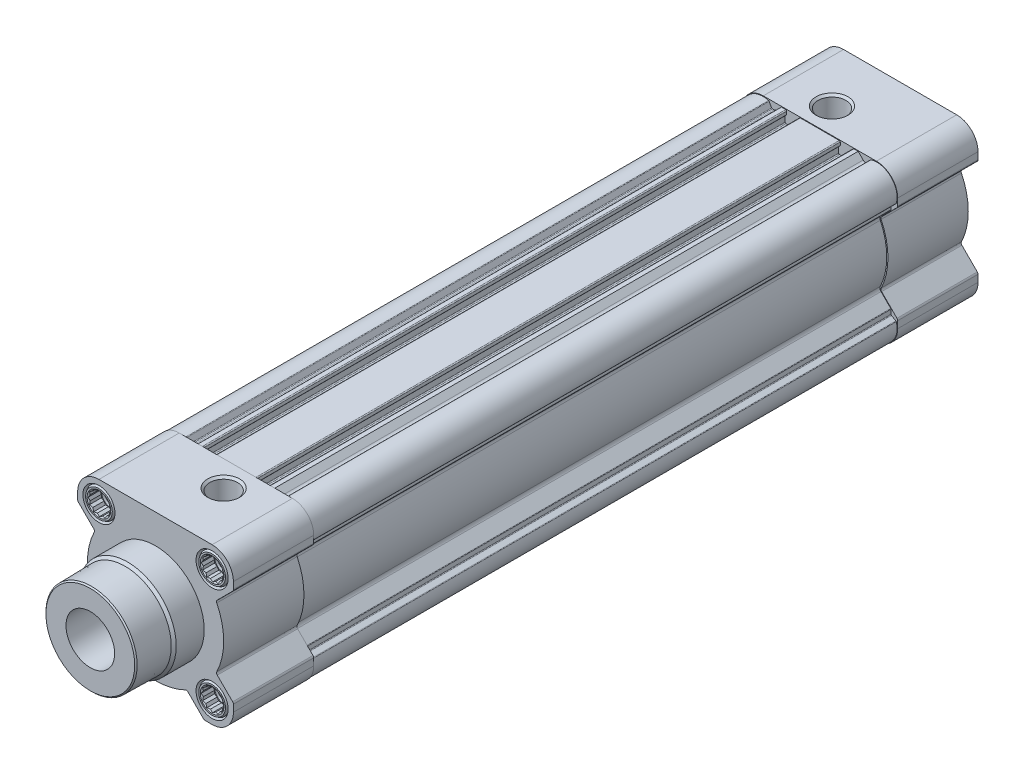
from build123d import *

# Parameters (mm, degrees)
BOSS_EXTRUDE1_DEPTH  = 33
BOSS_EXTRUDE2_DEPTH  = 240
SKETCH3_W            = 76.8
SKETCH3_H            = 76.8
CUT_EXTRUDE1_DEPTH   = 240
BOSS_EXTRUDE3_DEPTH  = 33
SKETCH7_W            = 24.5
SKETCH7_H            = 6.6
LPATTERN1_COUNT      = 2
LPATTERN1_PITCH      = 46.5
LPATTERN1_COUNT_DIR2 = 2
LPATTERN1_PITCH_DIR2 = 46.5
LPATTERN2_COUNT      = 2
LPATTERN2_PITCH      = 46.5
LPATTERN2_COUNT_DIR2 = 2
LPATTERN2_PITCH_DIR2 = 46.5
CUT_EXTRUDE2_DEPTH   = 5
LPATTERN3_COUNT      = 2
LPATTERN3_PITCH      = 46.5
LPATTERN3_COUNT_DIR2 = 2
LPATTERN3_PITCH_DIR2 = 46.5
LPATTERN4_COUNT      = 2
LPATTERN4_PITCH      = 46.5
LPATTERN4_COUNT_DIR2 = 2
LPATTERN4_PITCH_DIR2 = 46.5
SKETCH17_W           = 24.5
SKETCH17_H           = 6.6
LPATTERN5_COUNT      = 2
LPATTERN5_PITCH      = 46.5
LPATTERN5_COUNT_DIR2 = 2
LPATTERN5_PITCH_DIR2 = 46.5
LPATTERN6_COUNT      = 2
LPATTERN6_PITCH      = 46.5
LPATTERN6_COUNT_DIR2 = 2
LPATTERN6_PITCH_DIR2 = 46.5
LPATTERN7_COUNT      = 2
LPATTERN7_PITCH      = 46.5
LPATTERN7_COUNT_DIR2 = 2
LPATTERN7_PITCH_DIR2 = 46.5
CUT_EXTRUDE3_DEPTH   = 5
LPATTERN8_COUNT      = 2
LPATTERN8_PITCH      = 46.5
LPATTERN8_COUNT_DIR2 = 2
LPATTERN8_PITCH_DIR2 = 46.5


with BuildPart() as part:
    # Sketch1 → Boss-Extrude1 (new body)
    with BuildSketch(Plane.XY.offset(-33)):
        with BuildLine():
            Line((-31.707106781, 19.686291501), (-25.38500441, 13.36418913))
            ThreePointArc((-25.38500441, 13.36418913), (-25.10600235, 12.82318278), (-25.192383219, 12.220631233))
            ThreePointArc((-25.192383219, 12.220631233), (-28, 0), (-25.192383219, -12.220631233))
            ThreePointArc((-25.192383219, -12.220631233), (-25.10600235, -12.82318278), (-25.38500441, -13.36418913))
            Line((-25.38500441, -13.36418913), (-31.707106781, -19.686291501))
            ThreePointArc((-31.707106781, -19.686291501), (-31.923879533, -20.01071485), (-32, -20.393398282))
            Line((-32, -20.393398282), (-32, -23.25))
            ThreePointArc((-32, -23.25), (-29.437184335, -29.437184335), (-23.25, -32))
            Line((-23.25, -32), (-20.393398282, -32))
            ThreePointArc((-20.393398282, -32), (-20.01071485, -31.923879533), (-19.686291501, -31.707106781))
            Line((-19.686291501, -31.707106781), (-13.36418913, -25.38500441))
            ThreePointArc((-13.36418913, -25.38500441), (-12.82318278, -25.10600235), (-12.220631233, -25.192383219))
            ThreePointArc((-12.220631233, -25.192383219), (0, -28), (12.220631233, -25.192383219))
            ThreePointArc((12.220631233, -25.192383219), (12.82318278, -25.10600235), (13.36418913, -25.38500441))
            Line((13.36418913, -25.38500441), (19.686291501, -31.707106781))
            ThreePointArc((19.686291501, -31.707106781), (20.01071485, -31.923879533), (20.393398282, -32))
            Line((20.393398282, -32), (23.25, -32))
            ThreePointArc((23.25, -32), (29.437184335, -29.437184335), (32, -23.25))
            Line((32, -23.25), (32, -20.393398282))
            ThreePointArc((32, -20.393398282), (31.923879533, -20.01071485), (31.707106781, -19.686291501))
            Line((31.707106781, -19.686291501), (25.38500441, -13.36418913))
            ThreePointArc((25.38500441, -13.36418913), (25.10600235, -12.82318278), (25.192383219, -12.220631233))
            ThreePointArc((25.192383219, -12.220631233), (28, 0), (25.192383219, 12.220631233))
            ThreePointArc((25.192383219, 12.220631233), (25.10600235, 12.82318278), (25.38500441, 13.36418913))
            Line((25.38500441, 13.36418913), (31.707106781, 19.686291501))
            ThreePointArc((31.707106781, 19.686291501), (31.923879533, 20.01071485), (32, 20.393398282))
            Line((32, 20.393398282), (32, 23.25))
            ThreePointArc((32, 23.25), (29.437184335, 29.437184335), (23.25, 32))
            Line((23.25, 32), (-23.25, 32))
            ThreePointArc((-23.25, 32), (-29.437184335, 29.437184335), (-32, 23.25))
            Line((-32, 23.25), (-32, 20.393398282))
            ThreePointArc((-32, 20.393398282), (-31.923879533, 20.01071485), (-31.707106781, 19.686291501))
        make_face()
    extrude(amount=BOSS_EXTRUDE1_DEPTH)

    # Sketch2 → Boss-Extrude2 (add)
    with BuildSketch(Plane.XY.offset(-33)):
        with BuildLine():
            Line((-31.75, -20.08273811), (-31.75, -23.5))
            ThreePointArc((-31.75, -23.5), (-29.333630945, -29.333630945), (-23.5, -31.75))
            Line((-23.5, -31.75), (-20.08273811, -31.75))
            Line((-20.08273811, -31.75), (-13.628865041, -25.296126931))
            ThreePointArc((-13.628865041, -25.296126931), (-12.822305384, -24.87846612), (-11.922577907, -25.00284256))
            ThreePointArc((-11.922577907, -25.00284256), (0, -27.7), (11.922577907, -25.00284256))
            ThreePointArc((11.922577907, -25.00284256), (12.822305384, -24.87846612), (13.628865041, -25.296126931))
            Line((13.628865041, -25.296126931), (20.08273811, -31.75))
            Line((20.08273811, -31.75), (23.5, -31.75))
            ThreePointArc((23.5, -31.75), (29.333630945, -29.333630945), (31.75, -23.5))
            Line((31.75, -23.5), (31.75, -20.08273811))
            Line((31.75, -20.08273811), (25.296126931, -13.628865041))
            ThreePointArc((25.296126931, -13.628865041), (24.87846612, -12.822305384), (25.00284256, -11.922577907))
            ThreePointArc((25.00284256, -11.922577907), (27.7, 0), (25.00284256, 11.922577907))
            ThreePointArc((25.00284256, 11.922577907), (24.87846612, 12.822305384), (25.296126931, 13.628865041))
            Line((25.296126931, 13.628865041), (31.75, 20.08273811))
            Line((31.75, 20.08273811), (31.75, 23.5))
            ThreePointArc((31.75, 23.5), (29.333630945, 29.333630945), (23.5, 31.75))
            Line((23.5, 31.75), (-23.5, 31.75))
            ThreePointArc((-23.5, 31.75), (-29.333630945, 29.333630945), (-31.75, 23.5))
            Line((-31.75, 23.5), (-31.75, 20.08273811))
            Line((-31.75, 20.08273811), (-25.296126931, 13.628865041))
            ThreePointArc((-25.296126931, 13.628865041), (-24.87846612, 12.822305384), (-25.00284256, 11.922577907))
            ThreePointArc((-25.00284256, 11.922577907), (-27.7, 0), (-25.00284256, -11.922577907))
            ThreePointArc((-25.00284256, -11.922577907), (-24.87846612, -12.822305384), (-25.296126931, -13.628865041))
            Line((-25.296126931, -13.628865041), (-31.75, -20.08273811))
        make_face()
    extrude(amount=-BOSS_EXTRUDE2_DEPTH)

    # Sketch3 → Cut-Extrude1 (cut)
    with BuildSketch(Plane.XY.offset(-33)):
        Rectangle(SKETCH3_W, SKETCH3_H)
        with BuildLine():
            Line((-20.847700821, -31.237836974), (-19.815492663, -29.45))
            ThreePointArc((-19.815492663, -29.45), (-19.669082502, -29.303589838), (-19.469082502, -29.25))
            Line((-19.469082502, -29.25), (-17.748423535, -29.25))
            ThreePointArc((-17.748423535, -29.25), (-17.595350162, -29.219551813), (-17.465580823, -29.132842712))
            Line((-17.465580823, -29.132842712), (-13.478767922, -25.146029812))
            ThreePointArc((-13.478767922, -25.146029812), (-12.674014627, -24.728680623), (-11.775791832, -24.851171536))
            ThreePointArc((-11.775791832, -24.851171536), (0, -27.5), (11.775791832, -24.851171536))
            ThreePointArc((11.775791832, -24.851171536), (12.674014627, -24.728680623), (13.478767922, -25.146029812))
            Line((13.478767922, -25.146029812), (17.465580823, -29.132842712))
            ThreePointArc((17.465580823, -29.132842712), (17.595350162, -29.219551813), (17.748423535, -29.25))
            Line((17.748423535, -29.25), (19.469082502, -29.25))
            ThreePointArc((19.469082502, -29.25), (19.669082502, -29.303589838), (19.815492663, -29.45))
            Line((19.815492663, -29.45), (20.847700821, -31.237836974))
            ThreePointArc((20.847700821, -31.237836974), (20.947545902, -31.352806276), (21.083122856, -31.422130658))
            ThreePointArc((21.083122856, -31.422130658), (29.304341623, -29.304341623), (31.422130658, -21.083122856))
            ThreePointArc((31.422130658, -21.083122856), (31.352806276, -20.947545902), (31.237836974, -20.847700821))
            Line((31.237836974, -20.847700821), (29.45, -19.815492663))
            ThreePointArc((29.45, -19.815492663), (29.303589838, -19.669082502), (29.25, -19.469082502))
            Line((29.25, -19.469082502), (29.25, -17.748423535))
            ThreePointArc((29.25, -17.748423535), (29.219551813, -17.595350162), (29.132842712, -17.465580823))
            Line((29.132842712, -17.465580823), (25.146029812, -13.478767922))
            ThreePointArc((25.146029812, -13.478767922), (24.728680623, -12.674014627), (24.851171536, -11.775791832))
            ThreePointArc((24.851171536, -11.775791832), (27.5, 0), (24.851171536, 11.775791832))
            ThreePointArc((24.851171536, 11.775791832), (24.728680623, 12.674014627), (25.146029812, 13.478767922))
            Line((25.146029812, 13.478767922), (29.132842712, 17.465580823))
            ThreePointArc((29.132842712, 17.465580823), (29.219551813, 17.595350162), (29.25, 17.748423535))
            Line((29.25, 17.748423535), (29.25, 19.469082502))
            ThreePointArc((29.25, 19.469082502), (29.303589838, 19.669082502), (29.45, 19.815492663))
            Line((29.45, 19.815492663), (31.237836974, 20.847700821))
            ThreePointArc((31.237836974, 20.847700821), (31.352806276, 20.947545902), (31.422130658, 21.083122856))
            ThreePointArc((31.422130658, 21.083122856), (29.304341623, 29.304341623), (21.083122856, 31.422130658))
            ThreePointArc((21.083122856, 31.422130658), (20.947545902, 31.352806276), (20.847700821, 31.237836974))
            Line((20.847700821, 31.237836974), (19.815492663, 29.45))
            ThreePointArc((19.815492663, 29.45), (19.669082502, 29.303589838), (19.469082502, 29.25))
            Line((19.469082502, 29.25), (18.871320344, 29.25))
            ThreePointArc((18.871320344, 29.25), (18.297295195, 29.364180701), (17.810660172, 29.689339828))
            Line((17.810660172, 29.689339828), (15.75, 31.75))
            Line((15.75, 31.75), (14, 31.75))
            ThreePointArc((14, 31.75), (13.717157288, 31.632842712), (13.6, 31.35))
            Line((13.6, 31.35), (13.6, 30.15))
            ThreePointArc((13.6, 30.15), (13.658578644, 30.008578644), (13.8, 29.95))
            Line((13.8, 29.95), (14.05, 29.95))
            ThreePointArc((14.05, 29.95), (14.191421356, 29.891421356), (14.25, 29.75))
            Line((14.25, 29.75), (14.25, 27.15))
            ThreePointArc((14.25, 27.15), (14.132842712, 26.867157288), (13.85, 26.75))
            Line((13.85, 26.75), (8.15, 26.75))
            ThreePointArc((8.15, 26.75), (7.867157288, 26.867157288), (7.75, 27.15))
            Line((7.75, 27.15), (7.75, 29.75))
            ThreePointArc((7.75, 29.75), (7.808578644, 29.891421356), (7.95, 29.95))
            Line((7.95, 29.95), (8.2, 29.95))
            ThreePointArc((8.2, 29.95), (8.341421356, 30.008578644), (8.4, 30.15))
            Line((8.4, 30.15), (8.4, 31.35))
            ThreePointArc((8.4, 31.35), (8.282842712, 31.632842712), (8, 31.75))
            Line((8, 31.75), (-8, 31.75))
            ThreePointArc((-8, 31.75), (-8.282842712, 31.632842712), (-8.4, 31.35))
            Line((-8.4, 31.35), (-8.4, 30.15))
            ThreePointArc((-8.4, 30.15), (-8.341421356, 30.008578644), (-8.2, 29.95))
            Line((-8.2, 29.95), (-7.95, 29.95))
            ThreePointArc((-7.95, 29.95), (-7.808578644, 29.891421356), (-7.75, 29.75))
            Line((-7.75, 29.75), (-7.75, 27.15))
            ThreePointArc((-7.75, 27.15), (-7.867157288, 26.867157288), (-8.15, 26.75))
            Line((-8.15, 26.75), (-13.85, 26.75))
            ThreePointArc((-13.85, 26.75), (-14.132842712, 26.867157288), (-14.25, 27.15))
            Line((-14.25, 27.15), (-14.25, 29.75))
            ThreePointArc((-14.25, 29.75), (-14.191421356, 29.891421356), (-14.05, 29.95))
            Line((-14.05, 29.95), (-13.8, 29.95))
            ThreePointArc((-13.8, 29.95), (-13.658578644, 30.008578644), (-13.6, 30.15))
            Line((-13.6, 30.15), (-13.6, 31.35))
            ThreePointArc((-13.6, 31.35), (-13.717157288, 31.632842712), (-14, 31.75))
            Line((-14, 31.75), (-15.75, 31.75))
            Line((-15.75, 31.75), (-17.810660172, 29.689339828))
            ThreePointArc((-17.810660172, 29.689339828), (-18.297295195, 29.364180701), (-18.871320344, 29.25))
            Line((-18.871320344, 29.25), (-19.469082502, 29.25))
            ThreePointArc((-19.469082502, 29.25), (-19.669082502, 29.303589838), (-19.815492663, 29.45))
            Line((-19.815492663, 29.45), (-20.847700821, 31.237836974))
            ThreePointArc((-20.847700821, 31.237836974), (-20.947545902, 31.352806276), (-21.083122856, 31.422130658))
            ThreePointArc((-21.083122856, 31.422130658), (-29.304341623, 29.304341623), (-31.422130658, 21.083122856))
            ThreePointArc((-31.422130658, 21.083122856), (-31.352806276, 20.947545902), (-31.237836974, 20.847700821))
            Line((-31.237836974, 20.847700821), (-29.45, 19.815492663))
            ThreePointArc((-29.45, 19.815492663), (-29.303589838, 19.669082502), (-29.25, 19.469082502))
            Line((-29.25, 19.469082502), (-29.25, 17.748423535))
            ThreePointArc((-29.25, 17.748423535), (-29.219551813, 17.595350162), (-29.132842712, 17.465580823))
            Line((-29.132842712, 17.465580823), (-25.146029812, 13.478767922))
            ThreePointArc((-25.146029812, 13.478767922), (-24.728680623, 12.674014627), (-24.851171536, 11.775791832))
            ThreePointArc((-24.851171536, 11.775791832), (-27.5, 0), (-24.851171536, -11.775791832))
            ThreePointArc((-24.851171536, -11.775791832), (-24.728680623, -12.674014627), (-25.146029812, -13.478767922))
            Line((-25.146029812, -13.478767922), (-29.132842712, -17.465580823))
            ThreePointArc((-29.132842712, -17.465580823), (-29.219551813, -17.595350162), (-29.25, -17.748423535))
            Line((-29.25, -17.748423535), (-29.25, -19.469082502))
            ThreePointArc((-29.25, -19.469082502), (-29.303589838, -19.669082502), (-29.45, -19.815492663))
            Line((-29.45, -19.815492663), (-31.237836974, -20.847700821))
            ThreePointArc((-31.237836974, -20.847700821), (-31.352806276, -20.947545902), (-31.422130658, -21.083122856))
            ThreePointArc((-31.422130658, -21.083122856), (-29.304341623, -29.304341623), (-21.083122856, -31.422130658))
            ThreePointArc((-21.083122856, -31.422130658), (-20.947545902, -31.352806276), (-20.847700821, -31.237836974))
        make_face(mode=Mode.SUBTRACT)
    extrude(amount=-CUT_EXTRUDE1_DEPTH, mode=Mode.SUBTRACT)

    # Sketch4 → Boss-Extrude3 (add)
    with BuildSketch(Plane.XY.offset(-306)):
        with BuildLine():
            Line((-31.707106781, 19.686291501), (-25.38500441, 13.36418913))
            ThreePointArc((-25.38500441, 13.36418913), (-25.10600235, 12.82318278), (-25.192383219, 12.220631233))
            ThreePointArc((-25.192383219, 12.220631233), (-28, 0), (-25.192383219, -12.220631233))
            ThreePointArc((-25.192383219, -12.220631233), (-25.10600235, -12.82318278), (-25.38500441, -13.36418913))
            Line((-25.38500441, -13.36418913), (-31.707106781, -19.686291501))
            ThreePointArc((-31.707106781, -19.686291501), (-31.923879533, -20.01071485), (-32, -20.393398282))
            Line((-32, -20.393398282), (-32, -23.25))
            ThreePointArc((-32, -23.25), (-29.437184335, -29.437184335), (-23.25, -32))
            Line((-23.25, -32), (-20.393398282, -32))
            ThreePointArc((-20.393398282, -32), (-20.01071485, -31.923879533), (-19.686291501, -31.707106781))
            Line((-19.686291501, -31.707106781), (-13.36418913, -25.38500441))
            ThreePointArc((-13.36418913, -25.38500441), (-12.82318278, -25.10600235), (-12.220631233, -25.192383219))
            ThreePointArc((-12.220631233, -25.192383219), (0, -28), (12.220631233, -25.192383219))
            ThreePointArc((12.220631233, -25.192383219), (12.82318278, -25.10600235), (13.36418913, -25.38500441))
            Line((13.36418913, -25.38500441), (19.686291501, -31.707106781))
            ThreePointArc((19.686291501, -31.707106781), (20.01071485, -31.923879533), (20.393398282, -32))
            Line((20.393398282, -32), (23.25, -32))
            ThreePointArc((23.25, -32), (29.437184335, -29.437184335), (32, -23.25))
            Line((32, -23.25), (32, -20.393398282))
            ThreePointArc((32, -20.393398282), (31.923879533, -20.01071485), (31.707106781, -19.686291501))
            Line((31.707106781, -19.686291501), (25.38500441, -13.36418913))
            ThreePointArc((25.38500441, -13.36418913), (25.10600235, -12.82318278), (25.192383219, -12.220631233))
            ThreePointArc((25.192383219, -12.220631233), (28, 0), (25.192383219, 12.220631233))
            ThreePointArc((25.192383219, 12.220631233), (25.10600235, 12.82318278), (25.38500441, 13.36418913))
            Line((25.38500441, 13.36418913), (31.707106781, 19.686291501))
            ThreePointArc((31.707106781, 19.686291501), (31.923879533, 20.01071485), (32, 20.393398282))
            Line((32, 20.393398282), (32, 23.25))
            ThreePointArc((32, 23.25), (29.437184335, 29.437184335), (23.25, 32))
            Line((23.25, 32), (-23.25, 32))
            ThreePointArc((-23.25, 32), (-29.437184335, 29.437184335), (-32, 23.25))
            Line((-32, 23.25), (-32, 20.393398282))
            ThreePointArc((-32, 20.393398282), (-31.923879533, 20.01071485), (-31.707106781, 19.686291501))
        make_face()
    extrude(amount=BOSS_EXTRUDE3_DEPTH)

    # Sketch5 → Revolve1 (revolve)
    with BuildSketch(Plane(origin=(0, 0, 0), x_dir=(0, 0, -1), z_dir=(1, 0, 0))):
        Polygon((-26.8, 0), (-26.8, 18.241665039), (-26.3, 18.741665039), (-12.517765157, 18.982234843), (-11.5, 20), (0, 20), (0, 0), align=None)
    revolve(axis=Axis((0, 0, 0), (0, 0, 1)))

    # Sketch6 → Cut-Revolve1 (revolve, cut)
    with BuildSketch(Plane(origin=(5.5, 0, 0), x_dir=(0, 0, -1), z_dir=(1, 0, 0))):
        Polygon((22.5, 32), (29.0785, 32), (28.2225, 31.144), (28.2225, 0), (22.5, 0), align=None)
    revolve(axis=Axis((5.5, 0, -22.5), (0, 1, 0)), mode=Mode.SUBTRACT)

    # Sketch7 → Cut-Revolve2 (revolve, cut)
    with BuildSketch(Plane(origin=(23.25, 0, 0), x_dir=(0, 0, -1), z_dir=(1, 0, 0))):
        with Locations((12.25, 26.55)):
            Rectangle(SKETCH7_W, SKETCH7_H)
    cut_revolve2 = revolve(axis=Axis((23.25, 23.25, -24.5), (0, 0, 1)), mode=Mode.SUBTRACT)

    # LPattern1: Cut-Revolve2 2 × 2
    with Locations(*[(-i * LPATTERN1_PITCH, -j * LPATTERN1_PITCH_DIR2, 0) for i in range(LPATTERN1_COUNT) for j in range(LPATTERN1_COUNT_DIR2) if (i, j) != (0, 0)]):
        add(cut_revolve2, mode=Mode.SUBTRACT)

    # Sketch9 → Revolve2 (revolve)
    with BuildSketch(Plane(origin=(23.25, 0, 0), x_dir=(0, 0, -1), z_dir=(1, 0, 0))):
        Polygon((0, 23.25), (0, 28.730384758), (0.9, 29.25), (24.5, 29.25), (24.5, 23.25), align=None)
    revolve2 = revolve(axis=Axis((23.25, 23.25, -24.5), (0, 0, 1)))

    # LPattern2: Revolve2 2 × 2
    with Locations(*[(-i * LPATTERN2_PITCH, -j * LPATTERN2_PITCH_DIR2, 0) for i in range(LPATTERN2_COUNT) for j in range(LPATTERN2_COUNT_DIR2) if (i, j) != (0, 0)]):
        add(revolve2)

    # Sketch11 → Cut-Revolve3 (revolve, cut)
    with BuildSketch(Plane(origin=(23.25, 0, 0), x_dir=(0, 0, -1), z_dir=(1, 0, 0))):
        Polygon((0, 23.25), (0, 28.1), (0.490747729, 27.25), (6, 27.25), (6.6765, 26.5735), (20.2, 26.5735), (22.11882362, 23.25), align=None)
    cut_revolve3 = revolve(axis=Axis((23.25, 23.25, -22.11882362), (0, 0, 1)), mode=Mode.SUBTRACT)

    # Sketch12 → Cut-Extrude2 (cut, symmetric)
    with BuildSketch(Plane.XY):
        Polygon((18.631197846, 23.25), (19.25, 22.17820323), (19.25, 20.940598923), (20.32179677, 20.32179677), (20.940598923, 19.25), (22.17820323, 19.25), (23.25, 18.631197846), (24.32179677, 19.25), (25.559401077, 19.25), (26.17820323, 20.32179677), (27.25, 20.940598923), (27.25, 22.17820323), (27.868802154, 23.25), (27.25, 24.32179677), (27.25, 25.559401077), (26.17820323, 26.17820323), (25.559401077, 27.25), (24.32179677, 27.25), (23.25, 27.868802154), (22.17820323, 27.25), (20.940598923, 27.25), (20.32179677, 26.17820323), (19.25, 25.559401077), (19.25, 24.32179677), align=None)
    cut_extrude2 = extrude(amount=CUT_EXTRUDE2_DEPTH, both=True, mode=Mode.SUBTRACT)

    # LPattern3: Cut-Revolve3 2 × 2
    with Locations(*[(-i * LPATTERN3_PITCH, -j * LPATTERN3_PITCH_DIR2, 0) for i in range(LPATTERN3_COUNT) for j in range(LPATTERN3_COUNT_DIR2) if (i, j) != (0, 0)]):
        add(cut_revolve3, mode=Mode.SUBTRACT)

    # LPattern4: Cut-Extrude2 2 × 2
    with Locations(*[(-i * LPATTERN4_PITCH, -j * LPATTERN4_PITCH_DIR2, 0) for i in range(LPATTERN4_COUNT) for j in range(LPATTERN4_COUNT_DIR2) if (i, j) != (0, 0)]):
        add(cut_extrude2, mode=Mode.SUBTRACT)

    # Sketch15 → Revolve3 (revolve)
    with BuildSketch(Plane(origin=(0, 0, 0), x_dir=(0, 0, -1), z_dir=(1, 0, 0))):
        Polygon((306, 0), (306, 20), (309.5, 20), (310, 19.5), (310, 0), align=None)
    revolve(axis=Axis((0, 0, -310), (0, 0, 1)))

    # Sketch16 → Cut-Revolve4 (revolve, cut)
    with BuildSketch(Plane(origin=(-5.5, 0, 0), x_dir=(0, 0, -1), z_dir=(1, 0, 0))):
        Polygon((283.5, 32), (290.0785, 32), (289.2225, 31.144), (289.2225, 0), (283.5, 0), align=None)
    revolve(axis=Axis((-5.5, 0, -283.5), (0, 1, 0)), mode=Mode.SUBTRACT)

    # Sketch17 → Cut-Revolve5 (revolve, cut)
    with BuildSketch(Plane(origin=(23.25, 0, 0), x_dir=(0, 0, -1), z_dir=(1, 0, 0))):
        with Locations((293.75, 26.55)):
            Rectangle(SKETCH17_W, SKETCH17_H)
    cut_revolve5 = revolve(axis=Axis((23.25, 23.25, -306), (0, 0, 1)), mode=Mode.SUBTRACT)

    # LPattern5: Cut-Revolve5 2 × 2
    with Locations(*[(-i * LPATTERN5_PITCH, -j * LPATTERN5_PITCH_DIR2, 0) for i in range(LPATTERN5_COUNT) for j in range(LPATTERN5_COUNT_DIR2) if (i, j) != (0, 0)]):
        add(cut_revolve5, mode=Mode.SUBTRACT)

    # Sketch19 → Revolve4 (revolve)
    with BuildSketch(Plane(origin=(23.25, 0, 0), x_dir=(0, 0, -1), z_dir=(1, 0, 0))):
        Polygon((281.5, 23.25), (281.5, 29.25), (305.1, 29.25), (306, 28.730384758), (306, 23.25), align=None)
    revolve4 = revolve(axis=Axis((23.25, 23.25, -306), (0, 0, 1)))

    # LPattern6: Revolve4 2 × 2
    with Locations(*[(-i * LPATTERN6_PITCH, -j * LPATTERN6_PITCH_DIR2, 0) for i in range(LPATTERN6_COUNT) for j in range(LPATTERN6_COUNT_DIR2) if (i, j) != (0, 0)]):
        add(revolve4)

    # Sketch21 → Cut-Revolve6 (revolve, cut)
    with BuildSketch(Plane(origin=(23.25, 0, 0), x_dir=(0, 0, -1), z_dir=(1, 0, 0))):
        Polygon((283.88117638, 23.25), (285.8, 26.5735), (299.3235, 26.5735), (300, 27.25), (305.509252271, 27.25), (306, 28.1), (306, 23.25), align=None)
    cut_revolve6 = revolve(axis=Axis((23.25, 23.25, -306), (0, 0, 1)), mode=Mode.SUBTRACT)

    # LPattern7: Cut-Revolve6 2 × 2
    with Locations(*[(-i * LPATTERN7_PITCH, -j * LPATTERN7_PITCH_DIR2, 0) for i in range(LPATTERN7_COUNT) for j in range(LPATTERN7_COUNT_DIR2) if (i, j) != (0, 0)]):
        add(cut_revolve6, mode=Mode.SUBTRACT)

    # Sketch23 → Cut-Extrude3 (cut, symmetric)
    with BuildSketch(Plane.XY.offset(-306)):
        Polygon((18.631197846, 23.25), (19.25, 22.17820323), (19.25, 20.940598923), (20.32179677, 20.32179677), (20.940598923, 19.25), (22.17820323, 19.25), (23.25, 18.631197846), (24.32179677, 19.25), (25.559401077, 19.25), (26.17820323, 20.32179677), (27.25, 20.940598923), (27.25, 22.17820323), (27.868802154, 23.25), (27.25, 24.32179677), (27.25, 25.559401077), (26.17820323, 26.17820323), (25.559401077, 27.25), (24.32179677, 27.25), (23.25, 27.868802154), (22.17820323, 27.25), (20.940598923, 27.25), (20.32179677, 26.17820323), (19.25, 25.559401077), (19.25, 24.32179677), align=None)
    cut_extrude3 = extrude(amount=CUT_EXTRUDE3_DEPTH, both=True, mode=Mode.SUBTRACT)

    # LPattern8: Cut-Extrude3 2 × 2
    with Locations(*[(-i * LPATTERN8_PITCH, -j * LPATTERN8_PITCH_DIR2, 0) for i in range(LPATTERN8_COUNT) for j in range(LPATTERN8_COUNT_DIR2) if (i, j) != (0, 0)]):
        add(cut_extrude3, mode=Mode.SUBTRACT)

    # Sketch25 → Cut-Revolve7 (revolve, cut)
    with BuildSketch(Plane(origin=(0, 0, 0), x_dir=(0, 0, -1), z_dir=(1, 0, 0))):
        Polygon((-26.8, 0), (-26.8, 10), (56.333333333, 10), (56.333333333, 25), (273, 25), (273, 0), align=None)
    revolve(axis=Axis((0, 0, -273), (0, 0, 1)), mode=Mode.SUBTRACT)


solid = part.part
